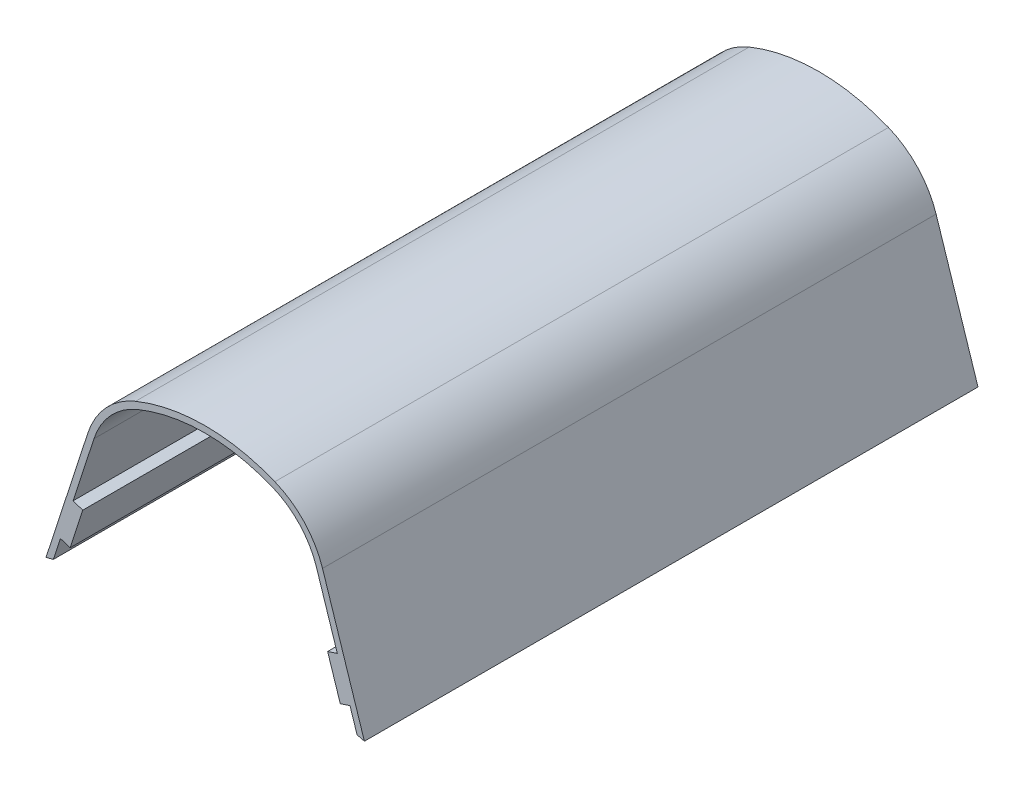
from build123d import *

# Parameters (mm, degrees)
BOSS_EXTRUDE2_DEPTH = 152.4


with BuildPart() as part:
    # Sketch1 → Boss-Extrude2 (new body)
    with BuildSketch(Plane.XY):
        with BuildLine():
            Line((37.717239544, 147.658964649), (35.965487423, 153.043027332))
            Line((35.965487423, 153.043027332), (33.550115758, 152.257164929))
            Line((33.550115758, 152.257164929), (30.406666146, 161.918651592))
            Line((30.406666146, 161.918651592), (32.822037812, 162.704513995))
            Line((32.822037812, 162.704513995), (32.036175409, 165.119885661))
            Line((32.036175409, 165.119885661), (27.627587493, 178.669812847))
            ThreePointArc((27.627587493, 178.669812847), (23.462294361, 185.748899875), (16.703713988, 190.41631151))
            ThreePointArc((16.703713988, 190.41631151), (0, 193.690277018), (-16.703713988, 190.41631151))
            ThreePointArc((-16.703713988, 190.41631151), (-23.462294361, 185.748899875), (-27.627587493, 178.669812847))
            Line((-27.627587493, 178.669812847), (-32.036175409, 165.119885661))
            Line((-32.036175409, 165.119885661), (-32.822037812, 162.704513995))
            Line((-32.822037812, 162.704513995), (-30.406666146, 161.918651592))
            Line((-30.406666146, 161.918651592), (-33.550115758, 152.257164929))
            Line((-33.550115758, 152.257164929), (-35.965487423, 153.043027332))
            Line((-35.965487423, 153.043027332), (-37.717239544, 147.658964649))
            ThreePointArc((-37.717239544, 147.658964649), (-38.630482432, 147.422677452), (-39.542245278, 147.180742077))
            Line((-39.542245278, 147.180742077), (-29.137194784, 179.160976849))
            ThreePointArc((-29.137194784, 179.160976849), (-24.624793891, 186.829987796), (-17.302998471, 191.886350359))
            ThreePointArc((-17.302998471, 191.886350359), (0, 195.277776974), (17.302998471, 191.886350359))
            ThreePointArc((17.302998471, 191.886350359), (24.624793891, 186.829987796), (29.137194784, 179.160976849))
            Line((29.137194784, 179.160976849), (39.542245278, 147.180742077))
            ThreePointArc((39.542245278, 147.180742077), (38.630482432, 147.422677452), (37.717239544, 147.658964649))
        make_face()
    extrude(amount=BOSS_EXTRUDE2_DEPTH)


solid = part.part
